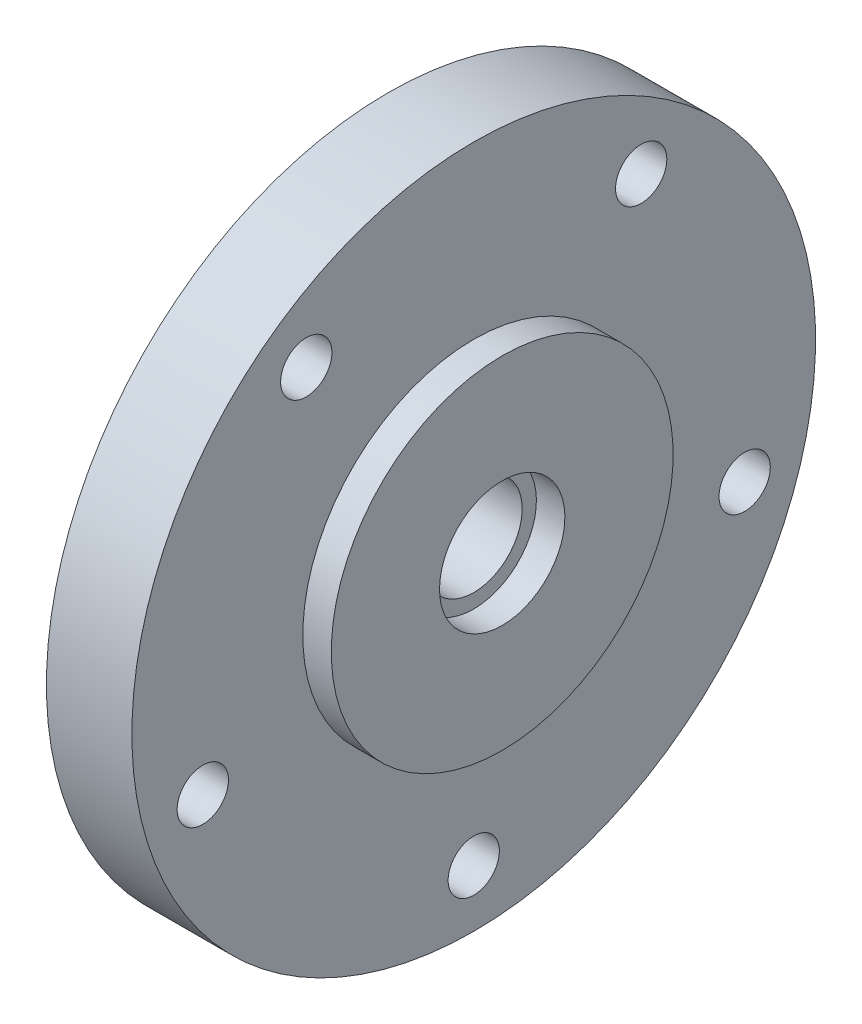
from build123d import *

# Parameters (mm, degrees)
M8_CLEARANCE_HOLE1_D     = 9
M8_CLEARANCE_HOLE1_DEPTH = 15
CIRPATTERN1_COUNT        = 5


with BuildPart() as part:
    # Sketch2 → Revolve1 (revolve)
    with BuildSketch(Plane.XY):
        Polygon((-5, 11), (0, 11), (0, 30), (-5, 30), (-5, 60), (-20, 60), (-20, 40), (-10, 40), (-10, 12.5), (-20, 12.5), (-20, 8.5), (-5, 8.5), align=None)
    revolve(axis=Axis((-20, 0, 0), (1, 0, 0)))

    # M8 Clearance Hole1
    with Locations(Plane(origin=(-5, -50, 0), x_dir=(0, 0, 1), z_dir=(1, 0, 0))):
        with Locations((0, 0)):
            m8_clearance_hole1 = Hole(M8_CLEARANCE_HOLE1_D / 2, depth=M8_CLEARANCE_HOLE1_DEPTH)

    # CirPattern1: M8 Clearance Hole1 ×5 about axis
    cirpattern1_axis = Axis((0, 0, 0), (1, 0, 0))
    for i in range(1, CIRPATTERN1_COUNT):
        add(m8_clearance_hole1.rotate(cirpattern1_axis, i * 360 / CIRPATTERN1_COUNT), mode=Mode.SUBTRACT)


solid = part.part
